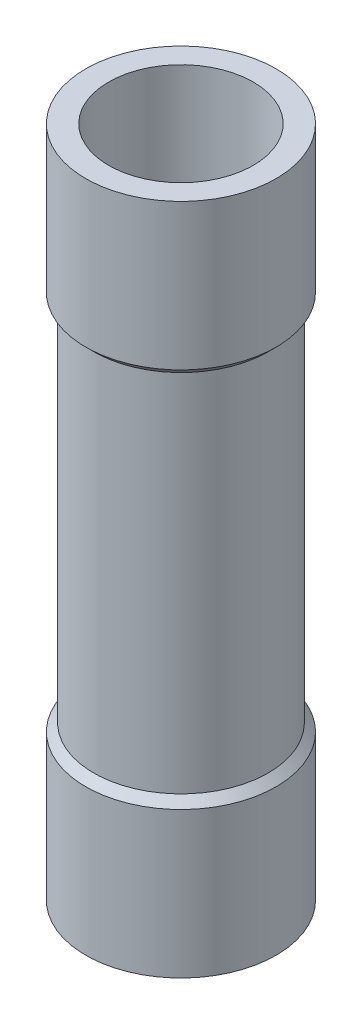
from build123d import *

# Parameters (mm, degrees)
SKETCH1_W = 1.2065
SKETCH1_H = 15.24


with BuildPart() as part:
    # Sketch1 → Revolve1 (revolve)
    with BuildSketch(Plane.XY):
        Polygon((2.894, 13.462), (2.894, -13.462), (3.81, -13.462), (3.81, -7.62), (3.4925, -7.3025), (3.4925, 7.3025), (3.81, 7.62), (3.81, 13.462), align=None)
        with Locations((2.19075, 0)):
            Rectangle(SKETCH1_W, SKETCH1_H)
    revolve(axis=Axis((0, 0, 0), (0, 1, 0)))


solid = part.part
